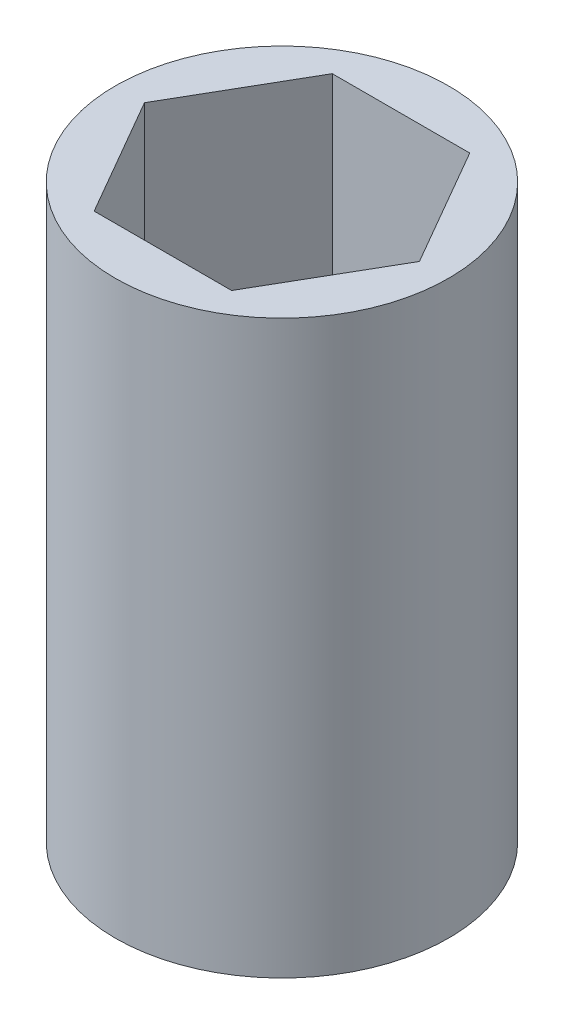
from build123d import *

# Parameters (mm, degrees)
SKETCH1_R           = 3.5
BOSS_EXTRUDE1_DEPTH = 12
CUT_EXTRUDE1_DEPTH  = 10


with BuildPart() as part:
    # Sketch1 → Boss-Extrude1 (new body)
    with BuildSketch(Plane(origin=(0, 0, 0), x_dir=(1, 0, 0), z_dir=(0, 1, 0))):
        Circle(SKETCH1_R)
    extrude(amount=BOSS_EXTRUDE1_DEPTH)

    # Sketch2 → Cut-Extrude1 (cut)
    with BuildSketch(Plane(origin=(0, 12, 0), x_dir=(1, 0, 0), z_dir=(0, 1, 0))):
        Polygon((2.886751346, 0), (1.443375673, 2.5), (-1.443375673, 2.5), (-2.886751346, 0), (-1.443375673, -2.5), (1.443375673, -2.5), align=None)
    extrude(amount=-CUT_EXTRUDE1_DEPTH, mode=Mode.SUBTRACT)


solid = part.part
